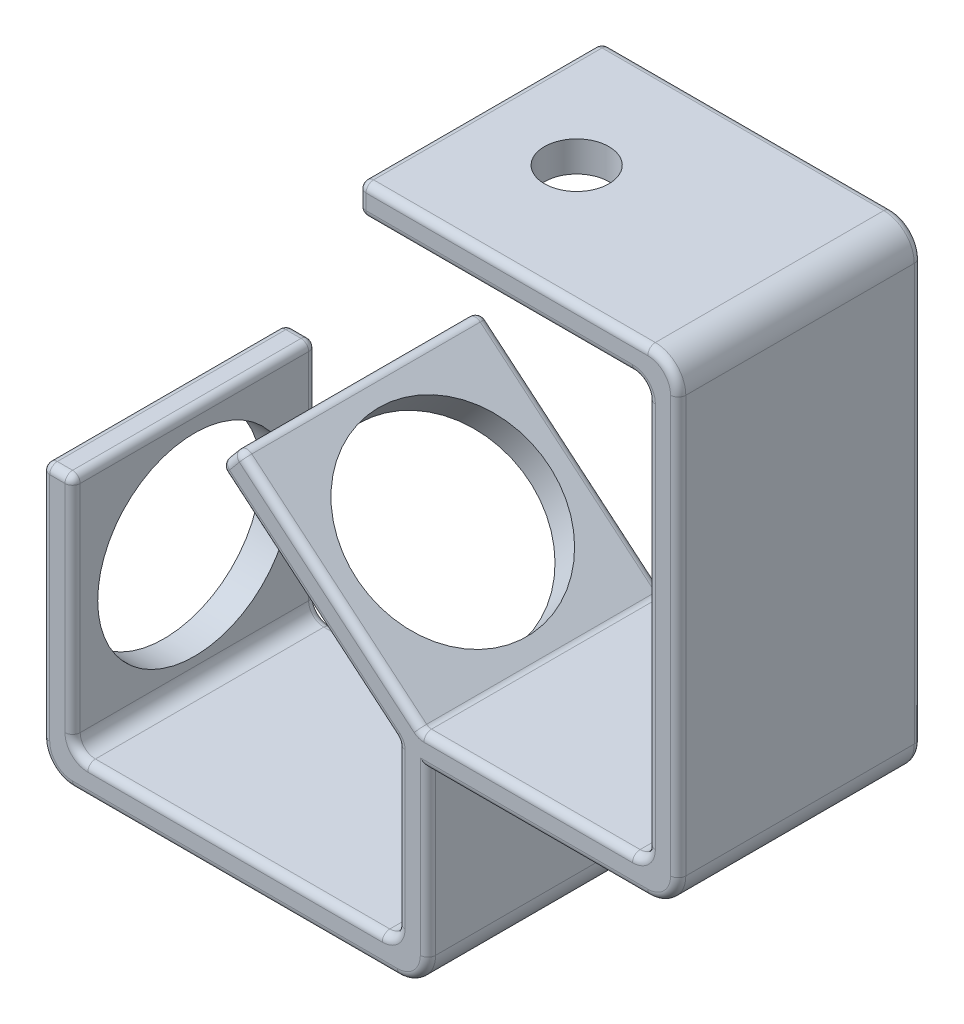
from build123d import *

# Parameters (mm, degrees)
EXTRUDE_THIN1_DEPTH = 48
BOSS_EXTRUDE1_DEPTH = 48
SKETCH3_R           = 19.05
CUT_EXTRUDE1_DEPTH  = 6
FILLET6_R           = 3
FILLET7_R           = 6
FILLET8_R           = 1.5
SKETCH4_R           = 6.35
CUT_EXTRUDE2_DEPTH  = 6
SKETCH5_R           = 19.05
CUT_EXTRUDE3_DEPTH  = 6


with BuildPart() as part:
    # Sketch1 → Extrude-Thin1 (new body)
    with BuildSketch(Plane.XY):
        Polygon((0, 53), (0, 0), (76, 0), (76, 38.2), (125.3, 38.2), (125.3, 132.2), (62.3, 132.2), (62.3, 126.2), (119.3, 126.2), (119.3, 44.2), (70, 44.2), (70, 6), (6, 6), (6, 53), align=None)
    extrude(amount=-EXTRUDE_THIN1_DEPTH)

    # Sketch2 → Boss-Extrude1 (add)
    with BuildSketch(Plane.XY):
        Polygon((70, 40.283778132), (34.806356996, 69.814750997), (38.663082654, 74.411017655), (74.667171481, 44.2), (70, 44.2), align=None)
    extrude(amount=-BOSS_EXTRUDE1_DEPTH)

    # Sketch3 → Cut-Extrude1 (cut)
    with BuildSketch(Plane.ZY):
        with Locations((-24, 29.8)):
            Circle(SKETCH3_R)
    extrude(amount=-CUT_EXTRUDE1_DEPTH, mode=Mode.SUBTRACT)

    # Fillet6
    fillet6_edges = [part.edges().sort_by_distance(p)[0] for p in [
        (6, 6, -24),
        (70, 6, -24),
        (119.3, 44.2, -24),
        (119.3, 126.2, -24),
    ]]
    fillet(fillet6_edges, radius=FILLET6_R)

    # Fillet7
    fillet7_edges = [part.edges().sort_by_distance(p)[0] for p in [
        (125.3, 132.2, -24),
        (125.3, 38.2, -24),
        (76, 0, -24),
        (0, 0, -24),
    ]]
    fillet(fillet7_edges, radius=FILLET7_R)

    # Fillet8
    fillet8_edges = [part.edges().sort_by_distance(p)[0] for p in [
        (97.65, 38.2, 0),
        (0, 29.5, 0),
        (3, 53, 0),
        (6, 31, 0),
        (62.3, 129.2, 0),
        (0, 53, -24),
        (6, 53, -24),
        (62.3, 126.2, -24),
        (62.3, 132.2, -24),
        (6, 31, -48),
        (3, 53, -48),
        (0, 29.5, -48),
        (95.48358574, 44.2, 0),
        (95.48358574, 44.2, -48),
        (52.403178498, 55.049264564, 0),
        (70, 40.283778132, -24),
        (36.734719825, 72.112884326, 0),
        (34.806356996, 69.814750997, -24),
        (56.665127067, 59.305508828, 0),
        (38.663082654, 74.411017655, -24),
        (74.667171481, 44.2, -24),
        (52.403178498, 55.049264564, -48),
        (36.734719825, 72.112884326, -48),
        (56.665127067, 59.305508828, -48),
        (97.65, 38.2, -48),
        (89.3, 126.2, 0),
        (89.3, 126.2, -48),
        (119.3, 85.2, 0),
        (119.3, 85.2, -48),
        (70, 24.641889066, -48),
        (70, 24.641889066, 0),
        (38, 6, 0),
        (38, 6, -48),
        (118.421320344, 125.321320344, 0),
        (118.421320344, 125.321320344, -48),
        (118.421320344, 45.078679656, 0),
        (118.421320344, 45.078679656, -48),
        (69.121320344, 6.878679656, 0),
        (69.121320344, 6.878679656, -48),
        (6.878679656, 6.878679656, 0),
        (6.878679656, 6.878679656, -48),
        (62.3, 129.2, -48),
        (125.3, 85.2, 0),
        (125.3, 85.2, -48),
        (38, 0, 0),
        (76, 22.1, 0),
        (90.8, 132.2, 0),
        (1.757359313, 1.757359313, 0),
        (74.242640687, 1.757359313, 0),
        (123.542640687, 39.957359313, 0),
        (123.542640687, 130.442640687, 0),
        (90.8, 132.2, -48),
        (76, 22.1, -48),
        (38, 0, -48),
        (1.757359313, 1.757359313, -48),
        (74.242640687, 1.757359313, -48),
        (123.542640687, 39.957359313, -48),
        (123.542640687, 130.442640687, -48),
    ]]
    fillet(fillet8_edges, radius=FILLET8_R)

    # Sketch4 → Cut-Extrude2 (cut)
    with BuildSketch(Plane(origin=(0, 132.2, 0), x_dir=(1, 0, 0), z_dir=(0, 1, 0))):
        with Locations((81.3, 24)):
            Circle(SKETCH4_R)
    extrude(amount=-CUT_EXTRUDE2_DEPTH, mode=Mode.SUBTRACT)

    # Sketch5 → Cut-Extrude3 (cut)
    with BuildSketch(Plane(origin=(52.614927952, 62.704029411, 0), x_dir=(0.766044443, -0.64278761, 0), z_dir=(0.64278761, 0.766044443, 0))):
        with Locations((5.587159448, 24)):
            Circle(SKETCH5_R)
    extrude(amount=-CUT_EXTRUDE3_DEPTH, mode=Mode.SUBTRACT)


solid = part.part
